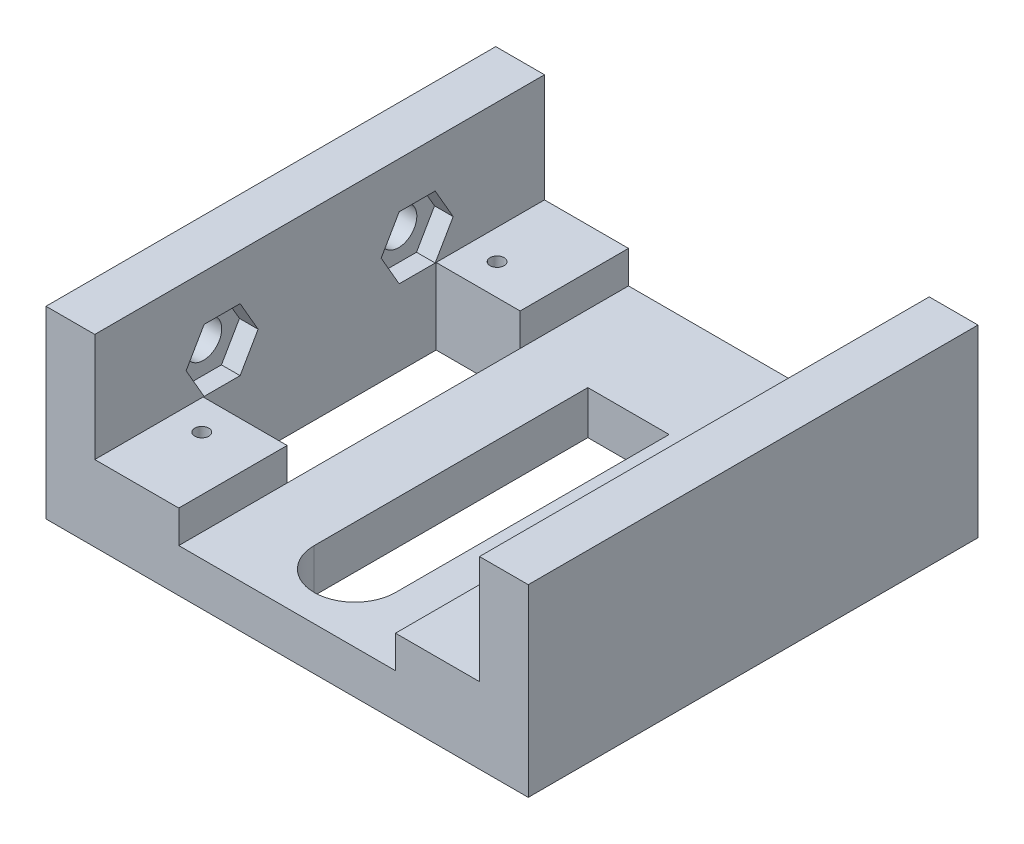
from build123d import *

# Parameters (mm, degrees)
SKETCH1_W                = 89
SKETCH1_H                = 83
SKETCH1_R                = 1.3
MAIN_BODY_DEPTH          = 14
SKETCH2_W                = 40
SKETCH2_H                = 83
SCREW_GROOVE_DEPTH       = 6
SKETCH4_W                = 9
SKETCH4_H                = 83
MOUNT_LIFT_DEPTH         = 20
MOUNT_START              = -5.55625
MOUNT_NUTS_DEPTH         = 18.94375
F_9_32_MOUNT_HOLES_REACH = 7.556
SKETCH5_R                = 3.3734375
SKETCH8_W                = 15.5
SKETCH8_H                = 43
MIDDLE_CUT_DEPTH         = 14


with BuildPart() as part:
    # Sketch1 → Main Body (new body)
    with BuildSketch(Plane(origin=(0, 0, 0), x_dir=(1, 0, 0), z_dir=(0, 1, 0))):
        with Locations((0, 41.5)):
            Rectangle(SKETCH1_W, SKETCH1_H)
        with Locations((-30, 14.25)):
            Circle(SKETCH1_R, mode=Mode.SUBTRACT)
        with Locations((30, 14.25)):
            Circle(SKETCH1_R, mode=Mode.SUBTRACT)
        with BuildLine():
            ThreePointArc((0, 5), (-5.303300859, 7.196699141), (-7.5, 12.5))
            Line((-7.5, 12.5), (-7.5, 63))
            Line((-7.5, 63), (7.5, 63))
            Line((7.5, 63), (7.5, 12.5))
            ThreePointArc((7.5, 12.5), (5.303300859, 7.196699141), (0, 5))
        make_face(mode=Mode.SUBTRACT)
        with Locations((-30, 68.75)):
            Circle(SKETCH1_R, mode=Mode.SUBTRACT)
        with Locations((30, 68.75)):
            Circle(SKETCH1_R, mode=Mode.SUBTRACT)
    extrude(amount=MAIN_BODY_DEPTH)

    # Sketch2 → Screw Groove (cut)
    with BuildSketch(Plane(origin=(0, 14, 0), x_dir=(1, 0, 0), z_dir=(0, 1, 0))):
        with Locations((0, 41.5)):
            Rectangle(SKETCH2_W, SKETCH2_H)
    extrude(amount=-SCREW_GROOVE_DEPTH, mode=Mode.SUBTRACT)

    # Sketch4 → Mount Lift (add)
    with BuildSketch(Plane(origin=(0, 14, 0), x_dir=(1, 0, 0), z_dir=(0, 1, 0))):
        with Locations((-40, 41.5)):
            Rectangle(SKETCH4_W, SKETCH4_H)
        with Locations((40, 41.5)):
            Rectangle(SKETCH4_W, SKETCH4_H)
    extrude(amount=MOUNT_LIFT_DEPTH)

    # Sketch6 → Mount Nuts (cut)
    with BuildSketch(Plane.ZY.offset(44.5).offset(MOUNT_START)):
        Polygon((-52.855059246, 19.7546875), (-56.177529623, 25.509375), (-62.822470377, 25.509375), (-66.144940754, 19.7546875), (-62.822470377, 14), (-56.177529623, 14), align=None)
        Polygon((-16.855059246, 19.7546875), (-20.177529623, 25.509375), (-26.822470377, 25.509375), (-30.144940754, 19.7546875), (-26.822470377, 14), (-20.177529623, 14), align=None)
    extrude(amount=-MOUNT_NUTS_DEPTH, mode=Mode.SUBTRACT)

    # Sketch5 → 9/32 Mount Holes (cut, up to next)
    with BuildSketch(Plane.ZY.offset(38.94375), mode=Mode.PRIVATE) as f_9_32_mount_holes_sk1:
        with Locations((-59.5, 19.7546875)):
            Circle(SKETCH5_R)
    f_9_32_mount_holes_tool1 = extrude(f_9_32_mount_holes_sk1.sketch, amount=F_9_32_MOUNT_HOLES_REACH, mode=Mode.PRIVATE) & part.part
    add(f_9_32_mount_holes_tool1.solids().sort_by_distance((-38.94375, 19.754688, -59.5))[0], mode=Mode.SUBTRACT)
    # Sketch5 → 9/32 Mount Holes (cut, up to next)
    with BuildSketch(Plane.ZY.offset(38.94375), mode=Mode.PRIVATE) as f_9_32_mount_holes_sk2:
        with Locations((-23.5, 19.7546875)):
            Circle(SKETCH5_R)
    f_9_32_mount_holes_tool2 = extrude(f_9_32_mount_holes_sk2.sketch, amount=F_9_32_MOUNT_HOLES_REACH, mode=Mode.PRIVATE) & part.part
    add(f_9_32_mount_holes_tool2.solids().sort_by_distance((-38.94375, 19.754688, -23.5))[0], mode=Mode.SUBTRACT)

    # Sketch8 → Middle Cut (cut)
    with BuildSketch(Plane(origin=(0, 14, 0), x_dir=(1, 0, 0), z_dir=(0, 1, 0))):
        with Locations((-27.75, 41.5)):
            Rectangle(SKETCH8_W, SKETCH8_H)
        with Locations((27.75, 41.5)):
            Rectangle(SKETCH8_W, SKETCH8_H)
    extrude(amount=-MIDDLE_CUT_DEPTH, mode=Mode.SUBTRACT)


solid = part.part
